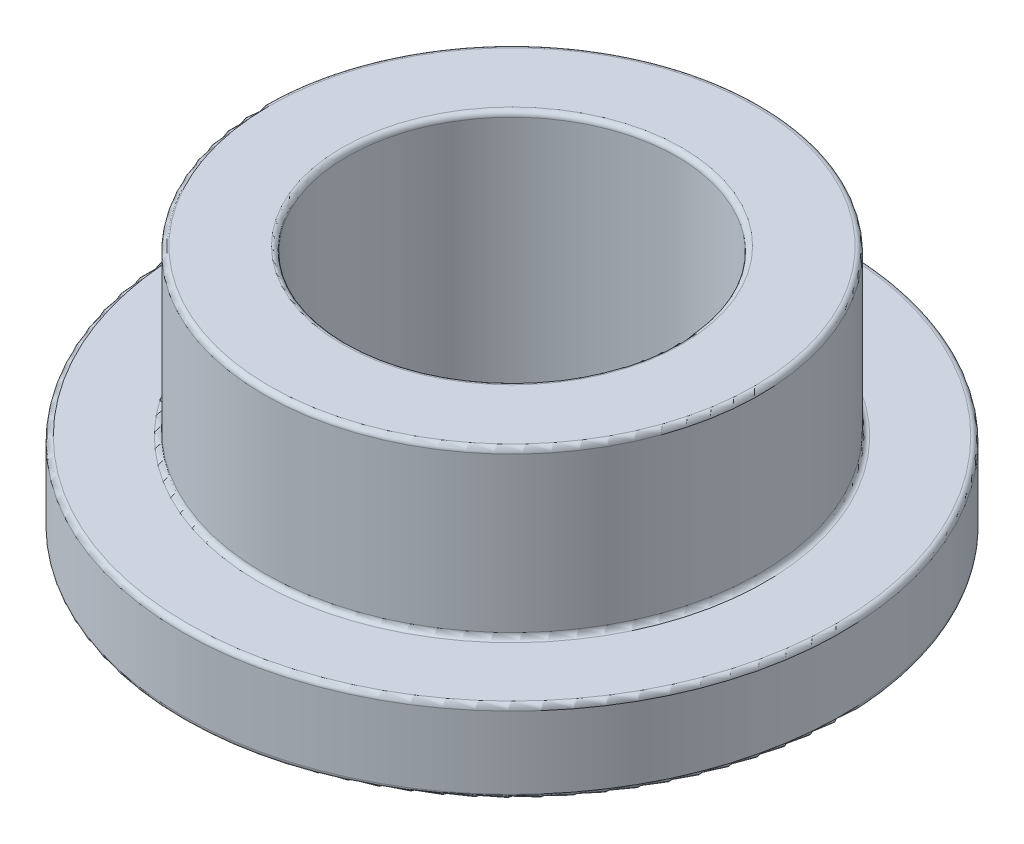
from build123d import *

# Parameters (mm, degrees)
SKETCH3_R           = 6.015
SKETCH3_R_2         = 4.005
BOSS_EXTRUDE1_DEPTH = 6
SKETCH4_R           = 8
SKETCH4_R_2         = 6.015
BOSS_EXTRUDE2_DEPTH = 2
FILLET1_R           = 0.125


with BuildPart() as part:
    # Sketch3 → Boss-Extrude1 (new body)
    with BuildSketch(Plane(origin=(0, 0, 0), x_dir=(1, 0, 0), z_dir=(0, 1, 0))):
        Circle(SKETCH3_R)
        Circle(SKETCH3_R_2, mode=Mode.SUBTRACT)
    extrude(amount=BOSS_EXTRUDE1_DEPTH)

    # Sketch4 → Boss-Extrude2 (add)
    with BuildSketch(Plane(origin=(0, 0, 0), x_dir=(1, 0, 0), z_dir=(0, 1, 0))):
        Circle(SKETCH4_R)
        Circle(SKETCH4_R_2, mode=Mode.SUBTRACT)
    extrude(amount=BOSS_EXTRUDE2_DEPTH)

    # Fillet1
    fillet1_edges = [part.edges().sort_by_distance(p)[0] for p in [
        (-8, 0, 0),
        (-6.015, 2, 0),
        (-6.015, 6, 0),
        (-4.005, 0, 0),
        (-4.005, 6, 0),
        (-8, 2, 0),
    ]]
    fillet(fillet1_edges, radius=FILLET1_R)


solid = part.part
